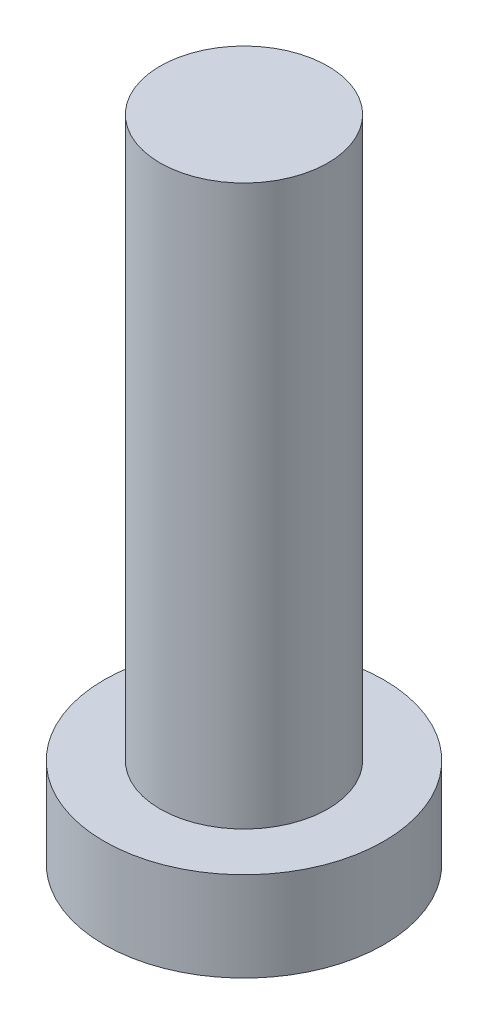
from build123d import *

# Parameters (mm, degrees)
SKETCH_1_R          = 2.5
EXTRUDE_1_DEPTH     = 1.6
SKETCH_2_R          = 1.5
EXTRUDE_2_DEPTH     = 10
CUT_EXTRUDE_1_DEPTH = 1


with BuildPart() as part:
    # 草图1 → 凸台-拉伸1 (new body)
    with BuildSketch(Plane(origin=(0, 0, 0), x_dir=(1, 0, 0), z_dir=(0, 1, 0))):
        Circle(SKETCH_1_R)
    extrude(amount=EXTRUDE_1_DEPTH)

    # 草图2 → 凸台-拉伸2 (add)
    with BuildSketch(Plane(origin=(0, 1.6, 0), x_dir=(1, 0, 0), z_dir=(0, 1, 0))):
        Circle(SKETCH_2_R)
    extrude(amount=EXTRUDE_2_DEPTH)

    # 草图3 → 切除-拉伸1 (cut)
    with BuildSketch(Plane.XZ):
        with BuildLine():
            Line((-0.5, 1), (-0.5, 1.75))
            Line((-0.5, 1.75), (0.5, 1.75))
            Line((0.5, 1.75), (0.5, 1))
            ThreePointArc((0.5, 1), (0.646446609, 0.646446609), (1, 0.5))
            Line((1, 0.5), (1.75, 0.5))
            Line((1.75, 0.5), (1.75, -0.5))
            Line((1.75, -0.5), (1, -0.5))
            ThreePointArc((1, -0.5), (0.646446609, -0.646446609), (0.5, -1))
            Line((0.5, -1), (0.5, -1.75))
            Line((0.5, -1.75), (-0.5, -1.75))
            Line((-0.5, -1.75), (-0.5, -1))
            ThreePointArc((-0.5, -1), (-0.646446609, -0.646446609), (-1, -0.5))
            Line((-1, -0.5), (-1.75, -0.5))
            Line((-1.75, -0.5), (-1.75, 0.5))
            Line((-1.75, 0.5), (-1, 0.5))
            ThreePointArc((-1, 0.5), (-0.646446609, 0.646446609), (-0.5, 1))
        make_face()
    extrude(amount=-CUT_EXTRUDE_1_DEPTH, mode=Mode.SUBTRACT)


solid = part.part
